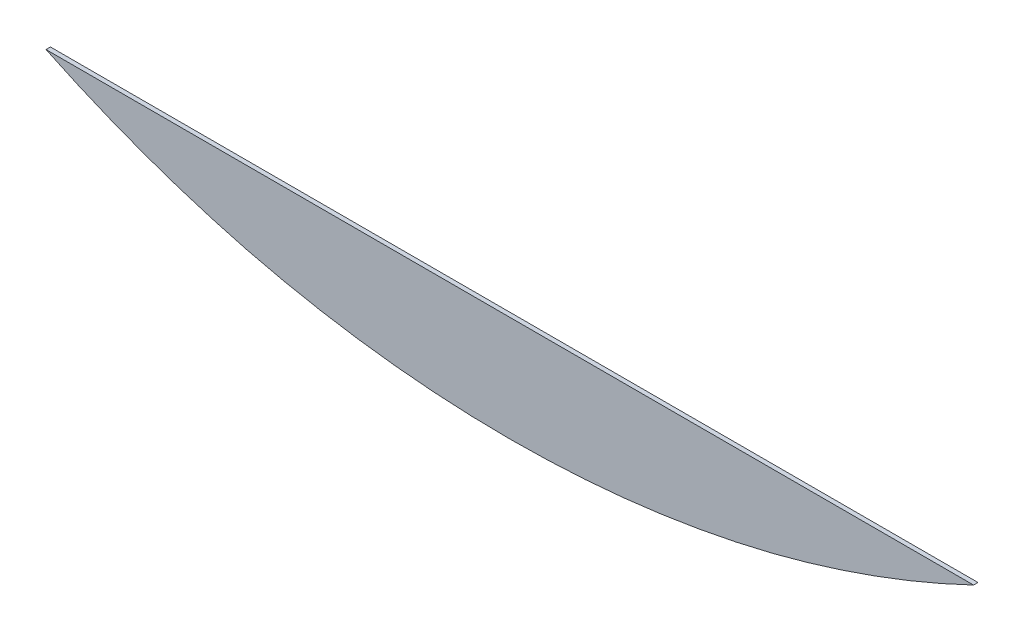
from build123d import *

# Parameters (mm, degrees)
BOSS_EXTRUDE1_DEPTH = 3.2004


with BuildPart() as part:
    # Sketch1 → Boss-Extrude1 (new body)
    with BuildSketch(Plane.XY):
        with BuildLine():
            Line((0, 0), (670.56, 0))
            ThreePointArc((670.56, 0), (599.468367444, -29.90962499), (525.78, -52.683083003))
            ThreePointArc((525.78, -52.683083003), (335.28, -76.2), (144.78, -52.683083003))
            ThreePointArc((144.78, -52.683083003), (71.091632556, -29.90962499), (0, 0))
        make_face()
    extrude(amount=BOSS_EXTRUDE1_DEPTH)


solid = part.part
